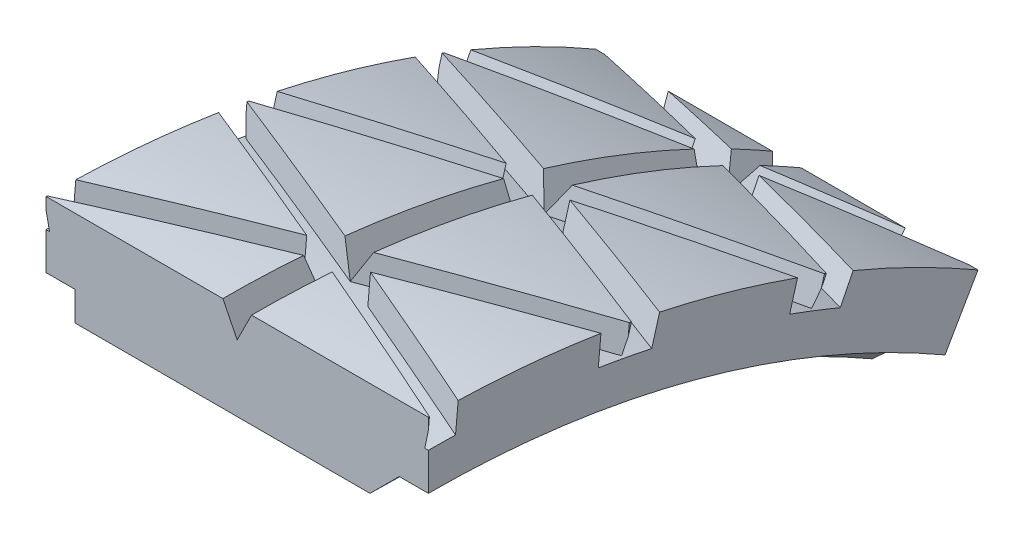
from build123d import *
from build123d.topology import SkipClean

# Parameters (mm, degrees)
CUT_EXTRUDE1_REACH      = 261.709
CUT_EXTRUDE1_END_RADIUS = 112
CIRPATTERN1_COUNT       = 34
SKETCH5_OUTSIDE_W       = 297.544
SKETCH5_OUTSIDE_H       = 297.544
CUT_EXTRUDE2_DEPTH      = 168.481342244


with BuildPart() as part:
    # Sketch1 → Revolve1 (revolve)
    with BuildSketch(Plane.XY, mode=Mode.PRIVATE) as revolve1_sk:
        Polygon((-20, 115), (20, 115), (20, 108.1), (16.95, 108.1), (13.9, 105.05), (-16.95, 105.05), (-16.95, 108.1), (-20, 108.1), align=None)
    revolve(revolve1_sk.sketch.rotate(Axis((22, 0, 0), (-1, 0, 0)), 90), axis=Axis((22, 0, 0), (-1, 0, 0)))

    # Cut-Extrude1: up to this cylinder (the profile starts outside it)
    cut_extrude1_end = Plane(origin=(0, 0, 0), z_dir=(-1, 0, 0)) * Cylinder(CUT_EXTRUDE1_END_RADIUS, 748.418, mode=Mode.PRIVATE)
    # Sketch3 → Cut-Extrude1 (cut, up to the surface)
    with BuildSketch(Plane.XY.offset(117), mode=Mode.PRIVATE) as cut_extrude1_sk1:
        Polygon((-20, 7.5), (-3.333333333, 0), (-20, -7.5), (-20, -10.5), (0, -1.5), (20, -10.5), (20, -7.5), (3.333333333, 0), (20, 7.5), (20, 10.5), (0, 1.5), (-20, 10.5), align=None)
    cut_extrude1_tool1 = extrude(cut_extrude1_sk1.sketch, amount=-CUT_EXTRUDE1_REACH, mode=Mode.PRIVATE) - cut_extrude1_end
    cut_extrude1 = cut_extrude1_tool1.solids().sort_by_distance((0, 0, 117))[0]
    add(cut_extrude1, mode=Mode.SUBTRACT)

    # CirPattern1: Cut-Extrude1 ×34 about axis
    with SkipClean():  # the faces are left unmerged after this step: merging them gives an invalid solid
        cirpattern1_axis = Axis((0, 0, 0), (1, 0, 0))
        for i in range(1, CIRPATTERN1_COUNT):
            add(cut_extrude1.rotate(cirpattern1_axis, i * 360 / CIRPATTERN1_COUNT), mode=Mode.SUBTRACT)

    # Sketch4 → Cut-Revolve1 (revolve, cut)
    with SkipClean():  # the faces are left unmerged after this step: merging them gives an invalid solid
        with BuildSketch(Plane.XY, mode=Mode.PRIVATE) as cut_revolve1_sk:
            Polygon((-1.5, 115), (1.5, 115), (0, 112), align=None)
        revolve(cut_revolve1_sk.sketch.rotate(Axis((22, 0, 0), (-1, 0, 0)), 270), axis=Axis((22, 0, 0), (-1, 0, 0)), mode=Mode.SUBTRACT)

    # Sketch5 outside → Cut-Extrude2 (cut, through all)
    with BuildSketch(Plane.ZY.offset(20)):
        Rectangle(SKETCH5_OUTSIDE_W, SKETCH5_OUTSIDE_H)
        with BuildLine():
            Line((0, 0), (0, 124.880273578))
            ThreePointArc((0, 124.880273578), (-34.133726301, 125.732826073), (-66.737856602, 115.593358423))
            Line((-66.737856602, 115.593358423), (0, 0))
        make_face(mode=Mode.SUBTRACT)
    extrude(amount=-CUT_EXTRUDE2_DEPTH, mode=Mode.SUBTRACT)


solid = part.part
